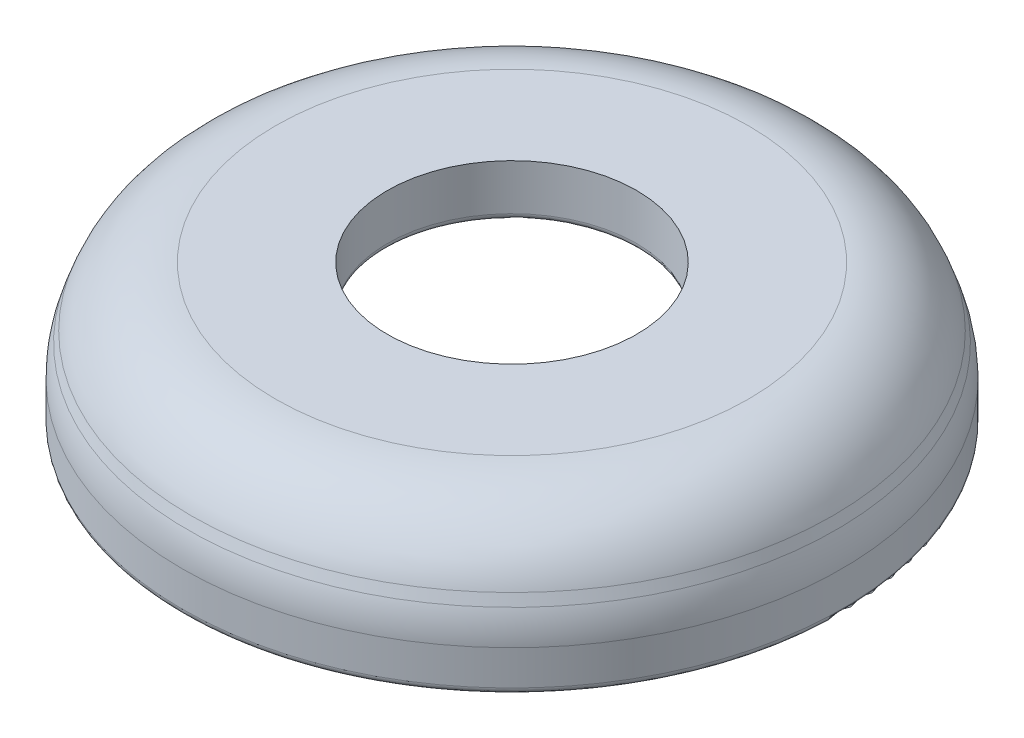
from build123d import *


with BuildPart() as part:
    # Sketch1 → Revolve1 (revolve)
    with BuildSketch(Plane.XY):
        with BuildLine():
            Line((4.75, 4.25), (9.016237468, 4.25))
            ThreePointArc((9.016237468, 4.25), (10.973568282, 3.628502604), (12.213835367, 1.991694585))
            Line((12.213835367, 1.991694585), (12.352608297, 1.600607236))
            ThreePointArc((12.352608297, 1.600607236), (12.505509699, 1.015806617), (12.55697426, 0.413542553))
            Line((12.55697426, 0.413542553), (12.55697426, -0.91549471))
            ThreePointArc((12.55697426, -0.91549471), (12.483750956, -1.092271405), (12.30697426, -1.16549471))
            Line((12.30697426, -1.16549471), (11.388512384, -1.16549471))
            ThreePointArc((11.388512384, -1.16549471), (11.2442914, -1.119701242), (11.152905448, -0.999097171))
            Line((11.152905448, -0.999097171), (10.083602461, 2.014393064))
            ThreePointArc((10.083602461, 2.014393064), (9.954206532, 2.185159746), (9.75, 2.25))
            Line((9.75, 2.25), (5, 2.25))
            ThreePointArc((5, 2.25), (4.823223305, 2.323223305), (4.75, 2.5))
            Line((4.75, 2.5), (4.75, 4.25))
        make_face()
    revolve(axis=Axis((0, -4.993282938, 0), (0, 1, 0)))


solid = part.part
